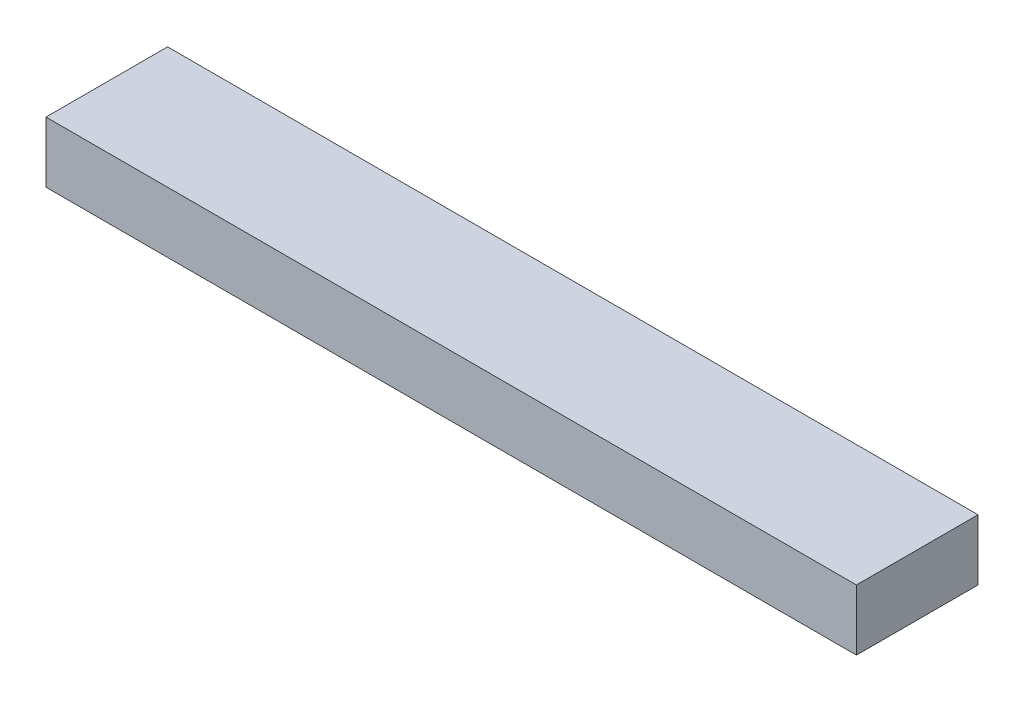
from build123d import *

# Parameters (mm, degrees)
SKETCH1_W           = 2000
SKETCH1_H           = 300
BOSS_EXTRUDE1_DEPTH = 75


with BuildPart() as part:
    # Sketch1 → Boss-Extrude1 (new body, symmetric)
    with BuildSketch(Plane(origin=(0, 0, 0), x_dir=(1, 0, 0), z_dir=(0, 1, 0))):
        Rectangle(SKETCH1_W, SKETCH1_H)
    extrude(amount=BOSS_EXTRUDE1_DEPTH, both=True)


solid = part.part
